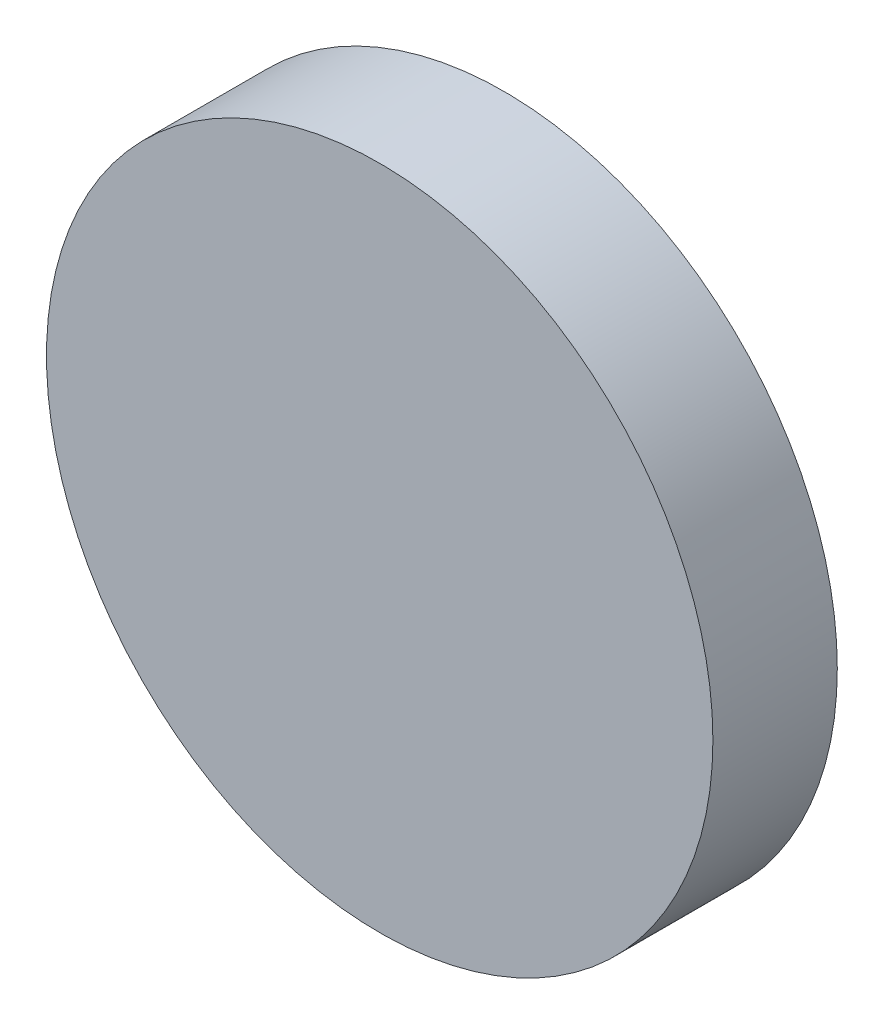
from build123d import *

# Parameters (mm, degrees)
MODEL_R                 = 8.035105677
SALIENTE_EXTRUIR1_DEPTH = 3


with BuildPart() as part:
    # Model → Saliente-Extruir1 (new body)
    with BuildSketch(Plane.XY):
        with Locations((50, 32.027364097)):
            Circle(MODEL_R)
    extrude(amount=SALIENTE_EXTRUIR1_DEPTH)


solid = part.part
